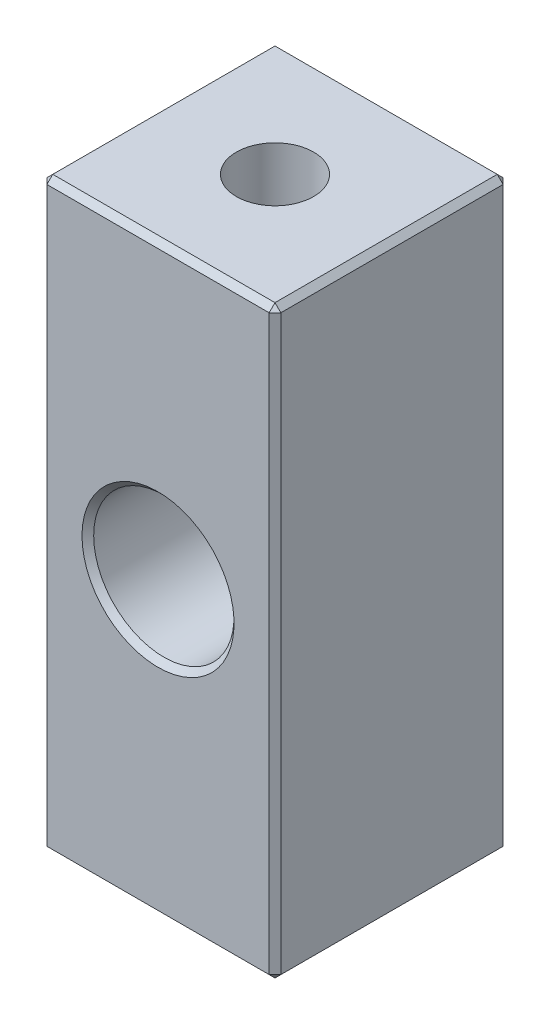
from build123d import *

# Parameters (mm, degrees)
SKETCH1_W                           = 10
SKETCH1_H                           = 25
EXTRUDE1_DEPTH                      = 10
SKETCH2_R                           = 3
CUT_EXTRUDE1_DEPTH                  = 10
M4X0_7_TAPPED_HOLE1_D               = 3.3
M4X0_7_TAPPED_HOLE1_DEPTH           = 8
M4X0_7_TAPPED_HOLE1_TIP             = 0.991420021
M4X0_7_TAPPED_HOLE1_ON_FACE_2_D     = 3.3
M4X0_7_TAPPED_HOLE1_ON_FACE_2_DEPTH = 8
M4X0_7_TAPPED_HOLE1_ON_FACE_2_TIP   = 0.991420021
CHAMFER1_SIZE                       = 0.25


with BuildPart() as part:
    # Sketch1 → Extrude1 (new body)
    with BuildSketch(Plane.XY):
        Rectangle(SKETCH1_W, SKETCH1_H)
    extrude(amount=EXTRUDE1_DEPTH)

    # Sketch2 → Cut-Extrude1 (cut)
    with BuildSketch(Plane.XY.offset(10)):
        Circle(SKETCH2_R)
    extrude(amount=-CUT_EXTRUDE1_DEPTH, mode=Mode.SUBTRACT)

    # M4x0.7 Tapped Hole1
    with Locations(Plane(origin=(0, 12.5, 5), x_dir=(0, 0, 1), z_dir=(0, 1, 0))):
        with Locations((0, 0)):
            Hole(M4X0_7_TAPPED_HOLE1_D / 2, depth=M4X0_7_TAPPED_HOLE1_DEPTH)
            with Locations((0, 0, -(M4X0_7_TAPPED_HOLE1_DEPTH + M4X0_7_TAPPED_HOLE1_TIP / 2))):  # 118° drill point
                Cone(0, M4X0_7_TAPPED_HOLE1_D / 2, M4X0_7_TAPPED_HOLE1_TIP, mode=Mode.SUBTRACT)

    # M4x0.7 Tapped Hole1 on face 2
    with Locations(Plane(origin=(0, -12.5, 5), x_dir=(0, 0, -1), z_dir=(0, -1, 0))):
        with Locations((0, 0)):
            Hole(M4X0_7_TAPPED_HOLE1_ON_FACE_2_D / 2, depth=M4X0_7_TAPPED_HOLE1_ON_FACE_2_DEPTH)
            with Locations((0, 0, -(M4X0_7_TAPPED_HOLE1_ON_FACE_2_DEPTH + M4X0_7_TAPPED_HOLE1_ON_FACE_2_TIP / 2))):  # 118° drill point
                Cone(0, M4X0_7_TAPPED_HOLE1_ON_FACE_2_D / 2, M4X0_7_TAPPED_HOLE1_ON_FACE_2_TIP, mode=Mode.SUBTRACT)

    # Chamfer1
    chamfer1_edges = [part.edges().sort_by_distance(p)[0] for p in [
        (5, 0, 10),
        (0, 12.5, 10),
        (-3, 0, 0),
        (-3, 0, 10),
        (-5, 0, 10),
        (0, 12.5, 0),
        (5, 0, 0),
        (0, -12.5, 0),
        (-5, 0, 0),
        (0, -12.5, 10),
        (-5, 12.5, 5),
        (5, 12.5, 5),
        (5, -12.5, 5),
        (-5, -12.5, 5),
    ]]
    chamfer(chamfer1_edges, length=CHAMFER1_SIZE)


solid = part.part
